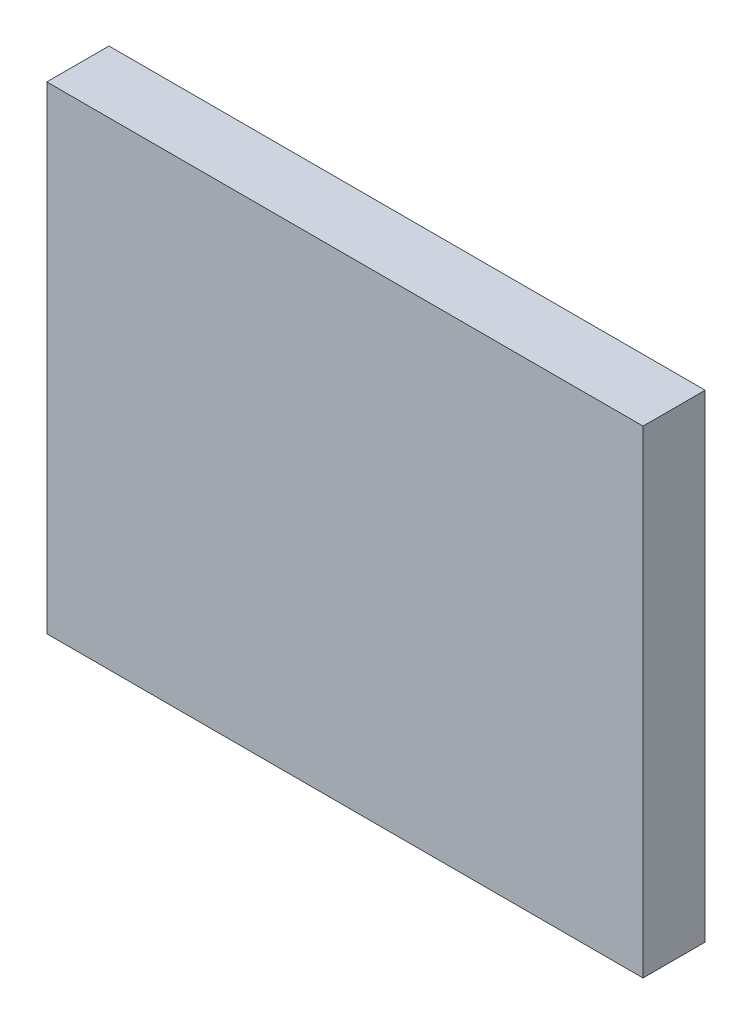
from build123d import *

# Parameters (mm, degrees)
SKETCH1_W           = 95.918226303
SKETCH1_H           = 76.893123566
BOSS_EXTRUDE1_DEPTH = 10


with BuildPart() as part:
    # Sketch1 → Boss-Extrude1 (new body)
    with BuildSketch(Plane.XY):
        with Locations((1.470881891, 0)):
            Rectangle(SKETCH1_W, SKETCH1_H)
    extrude(amount=BOSS_EXTRUDE1_DEPTH)


solid = part.part
